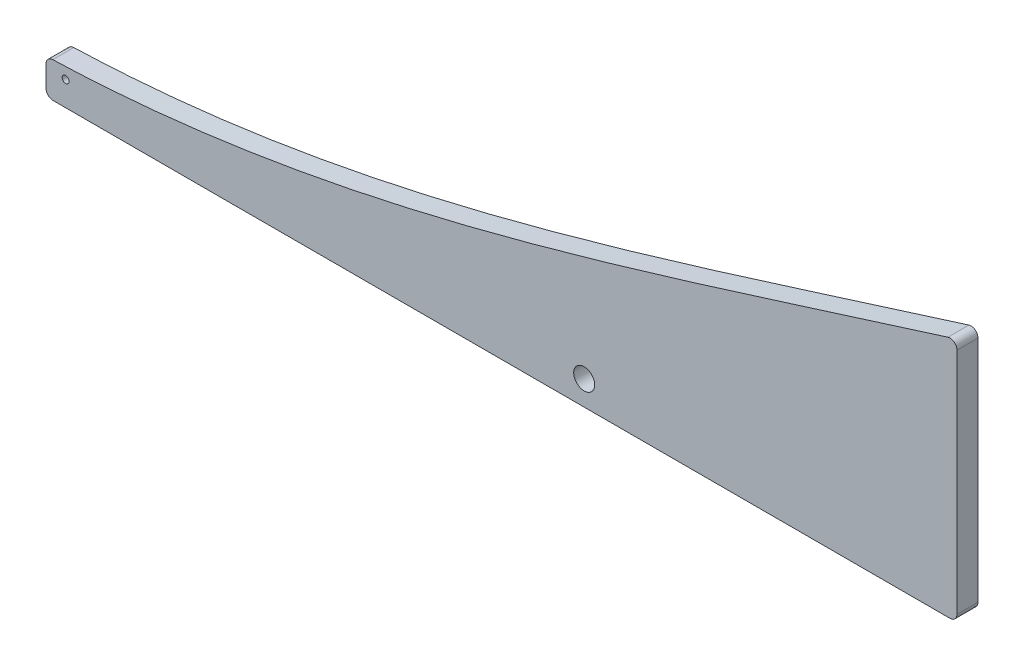
from build123d import *

# Parameters (mm, degrees)
SKETCH_1_R      = 0.5
SKETCH_1_R_2    = 1.5
EXTRUDE_1_DEPTH = 3
FILLET_1_R      = 1


with BuildPart() as part:
    # 草图1 → 凸台-拉伸1 (new body)
    with BuildSketch(Plane.XY):
        with BuildLine():
            Line((-34.1617357, 0), (95.8382643, 0))
            Line((95.8382643, 0), (95.8382643, 35))
            add(Edge.make_bspline(
                [(-34.1617357, 5), (10.689319489, 6.2279178), (53.602553401, 21.947320234), (95.8382643, 35)],
                knots=[0, 0, 0, 0, 1, 1, 1, 1], degree=3))
            Line((-34.1617357, 5), (-34.1617357, 0))
        make_face()
        with Locations((-31.3617357, 3.5)):
            Circle(SKETCH_1_R, mode=Mode.SUBTRACT)
        with Locations((42.6382643, 3.5)):
            Circle(SKETCH_1_R_2, mode=Mode.SUBTRACT)
    extrude(amount=EXTRUDE_1_DEPTH)

    # 圆角1
    fillet_1_edges = [part.edges().sort_by_distance(p)[0] for p in [
        (-34.1617357, 0, 1.5),
        (-34.1617357, 5, 1.5),
        (95.8382643, 35, 1.5),
        (95.8382643, 0, 1.5),
    ]]
    fillet(fillet_1_edges, radius=FILLET_1_R)


solid = part.part
